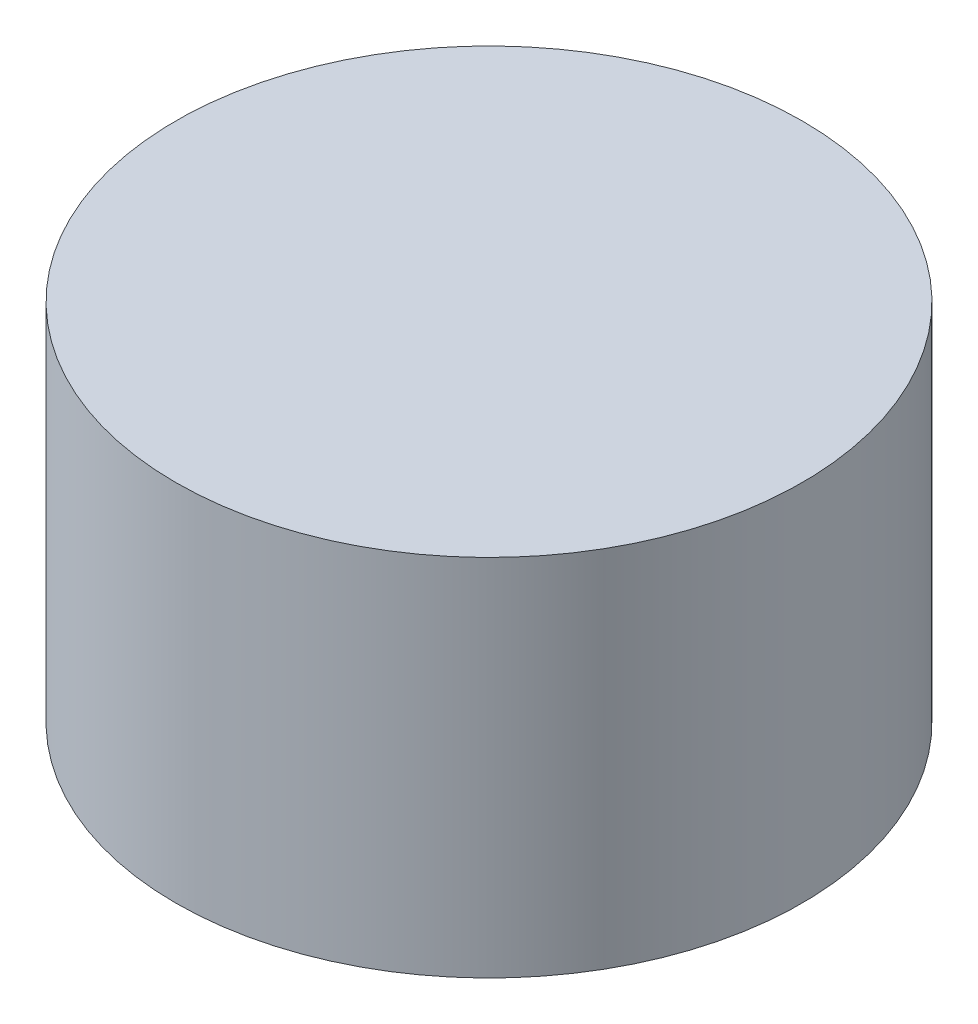
from build123d import *

# Parameters (mm, degrees)
SKETCH1_R           = 2.15
BOSS_EXTRUDE1_DEPTH = 2.5


with BuildPart() as part:
    # Sketch1 → Boss-Extrude1 (new body)
    with BuildSketch(Plane(origin=(0, 0, 0), x_dir=(1, 0, 0), z_dir=(0, 1, 0))):
        Circle(SKETCH1_R)
    extrude(amount=BOSS_EXTRUDE1_DEPTH)


solid = part.part
